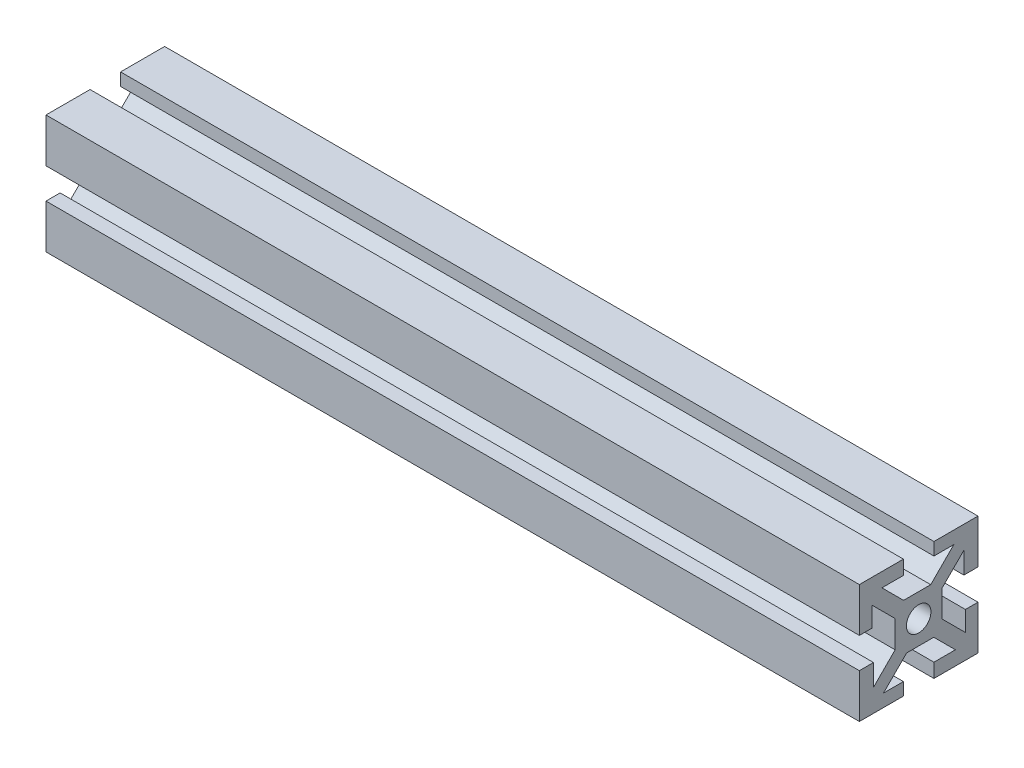
from build123d import *

# Parameters (mm, degrees)
SKETCH1_R           = 2.605
BOSS_EXTRUDE1_DEPTH = 172.72
CIRPATTERN1_COUNT   = 4
SKETCH2_R           = 2.38
CUT_EXTRUDE6_DEPTH  = 8


with BuildPart() as part:
    # Sketch1 → Boss-Extrude1 (new body)
    with BuildSketch(Plane(origin=(0, 0, 0), x_dir=(0, 0, -1), z_dir=(1, 0, 0))):
        Polygon((5, -5), (5, 3.203948776), (9.596194078, 7.800142853), (9.596194078, 3.24), (12.596194078, 3.24), (12.596194078, 12.596194078), (3.24, 12.596194078), (3.24, 9.921463197), (7.474873734, 9.921463197), (2.553410537, 5), (-5, 5), (-5, -5), align=None)
        Circle(SKETCH1_R, mode=Mode.SUBTRACT)
    boss_extrude1 = extrude(amount=BOSS_EXTRUDE1_DEPTH)

    # CirPattern1: Boss-Extrude1 ×4 about axis
    cirpattern1_axis = Axis((0, 0, 0), (1, 0, 0))
    for i in range(1, CIRPATTERN1_COUNT):
        add(boss_extrude1.rotate(cirpattern1_axis, i * 360 / CIRPATTERN1_COUNT))

    # Sketch2 → Cut-Extrude6 (cut)
    with BuildSketch(Plane.XY.offset(12.596194078)):
        with Locations((86.36, 0)):
            Circle(SKETCH2_R)
    extrude(amount=-CUT_EXTRUDE6_DEPTH, mode=Mode.SUBTRACT)


solid = part.part
